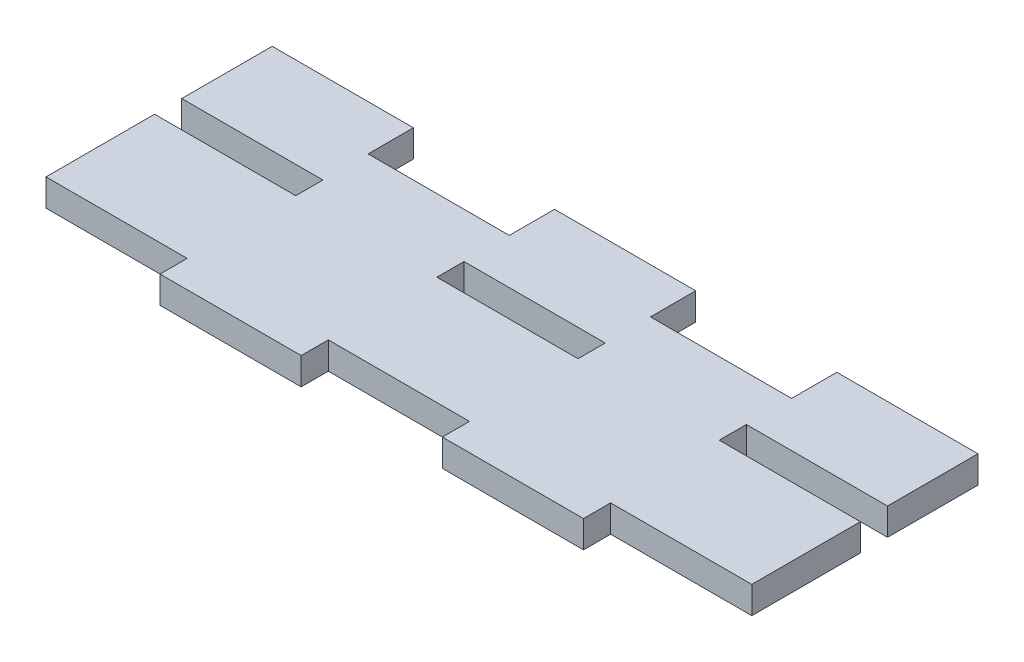
from build123d import *

# Parameters (mm, degrees)
SKETCH1_W           = 15.6
SKETCH1_H           = 3
BOSS_EXTRUDE1_DEPTH = 3


with BuildPart() as part:
    # Sketch1 → Boss-Extrude1 (new body)
    with BuildSketch(Plane(origin=(0, 0, 0), x_dir=(1, 0, 0), z_dir=(0, 1, 0))):
        Polygon((-23.4, 5), (-7.8, 5), (-7.8, 10), (7.8, 10), (7.8, 5), (23.4, 5), (23.4, 10), (39, 10), (39, 0), (23.4, 0), (23.4, -3), (39, -3), (39, -15), (23.4, -15), (23.4, -18), (7.8, -18), (7.8, -15), (-7.8, -15), (-7.8, -18), (-23.4, -18), (-23.4, -15), (-39, -15), (-39, -3), (-23.4, -3), (-23.4, 0), (-39, 0), (-39, 10), (-23.4, 10), align=None)
        with Locations((0, -1.5)):
            Rectangle(SKETCH1_W, SKETCH1_H, mode=Mode.SUBTRACT)
    extrude(amount=BOSS_EXTRUDE1_DEPTH)


solid = part.part
